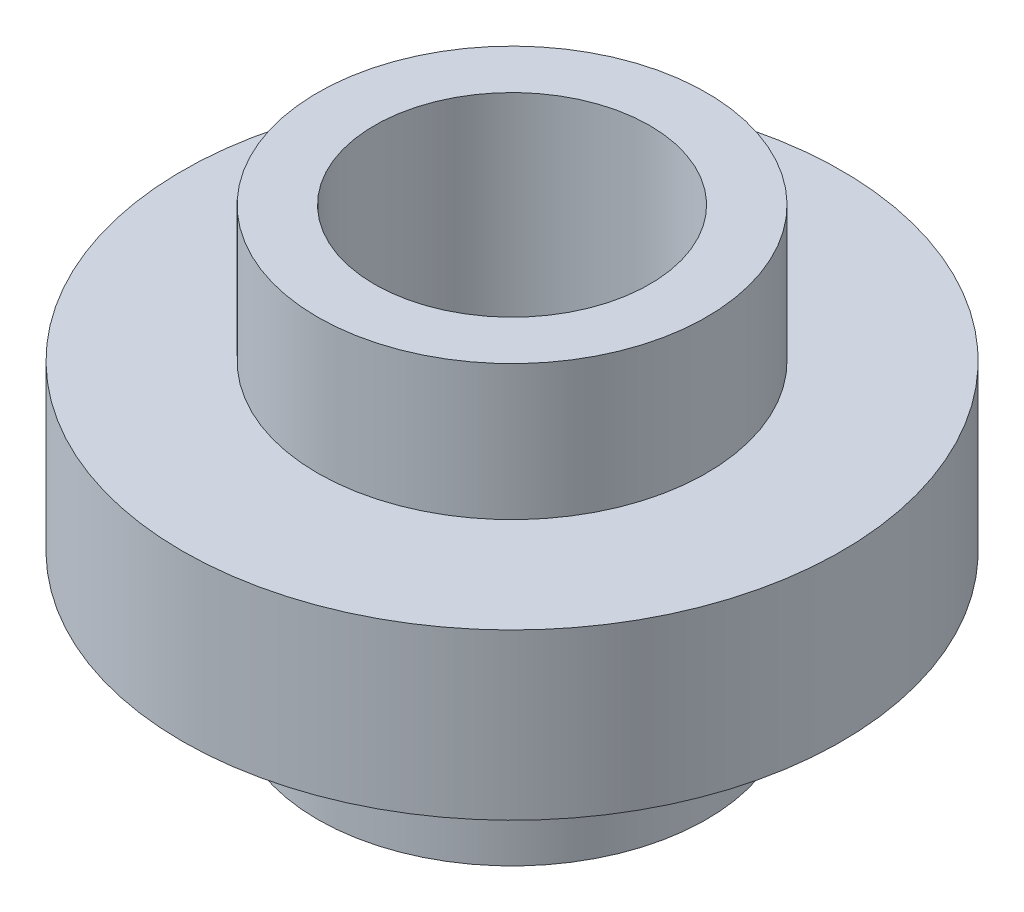
from build123d import *

# Parameters (mm, degrees)
SCHIZZO5_R               = 4.175
TAGLIO_ESTRUSIONE1_DEPTH = 14.2


with BuildPart() as part:
    # Schizzo2 → Rivoluzione1 (revolve)
    with BuildSketch(Plane(origin=(0, 0, 0), x_dir=(0, 0, -1), z_dir=(1, 0, 0))):
        Polygon((0, 6.6), (0, -6.6), (5.9, -6.6), (5.9, -2.5), (10, -2.5), (10, 2.5), (5.9, 2.5), (5.9, 6.6), align=None)
    revolve(axis=Axis((0, 6.6, 0), (0, -1, 0)))

    # Schizzo5 → Taglio-Estrusione1 (cut, through all)
    with BuildSketch(Plane(origin=(0, 6.6, 0), x_dir=(1, 0, 0), z_dir=(0, 1, 0))):
        Circle(SCHIZZO5_R)
    extrude(amount=-TAGLIO_ESTRUSIONE1_DEPTH, mode=Mode.SUBTRACT)


solid = part.part
